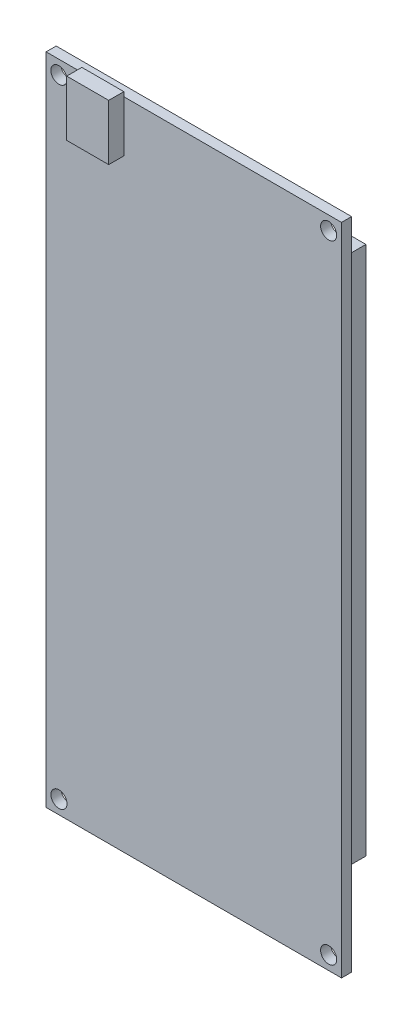
from build123d import *

# Parameters (mm, degrees)
SKETCH1_W           = 58.6
SKETCH1_H           = 129.8
SKETCH1_R           = 1.6
BOSS_EXTRUDE1_DEPTH = 2
SKETCH2_W           = 4.296297389
SKETCH2_H           = 105.080273626
SKETCH2_W_2         = 3.938272606
BOSS_EXTRUDE2_DEPTH = 9
SKETCH3_W           = 8.325714973
SKETCH3_H           = 11.044315781
BOSS_EXTRUDE3_DEPTH = 3


with BuildPart() as part:
    # Sketch1 → Boss-Extrude1 (new body)
    with BuildSketch(Plane.XY):
        Rectangle(SKETCH1_W, SKETCH1_H)
        with Locations((-26.75, 62.2)):
            Circle(SKETCH1_R, mode=Mode.SUBTRACT)
        with Locations((26.75, 62.2)):
            Circle(SKETCH1_R, mode=Mode.SUBTRACT)
        with Locations((-26.75, -62.2)):
            Circle(SKETCH1_R, mode=Mode.SUBTRACT)
        with Locations((26.75, -62.2)):
            Circle(SKETCH1_R, mode=Mode.SUBTRACT)
    extrude(amount=BOSS_EXTRUDE1_DEPTH)

    # Sketch2 → Boss-Extrude2 (add)
    with BuildSketch(Plane(origin=(0, 0, 0), x_dir=(-1, 0, 0), z_dir=(0, 0, -1))):
        with Locations((-20.989773544, 0)):
            Rectangle(SKETCH2_W, SKETCH2_H)
        with Locations((21.79418795, 0)):
            Rectangle(SKETCH2_W_2, SKETCH2_H)
    extrude(amount=BOSS_EXTRUDE2_DEPTH)

    # Sketch3 → Boss-Extrude3 (add)
    with BuildSketch(Plane.XY.offset(2)):
        with Locations((-18.042212682, 60.253196822)):
            Rectangle(SKETCH3_W, SKETCH3_H)
    extrude(amount=BOSS_EXTRUDE3_DEPTH)


solid = part.part
